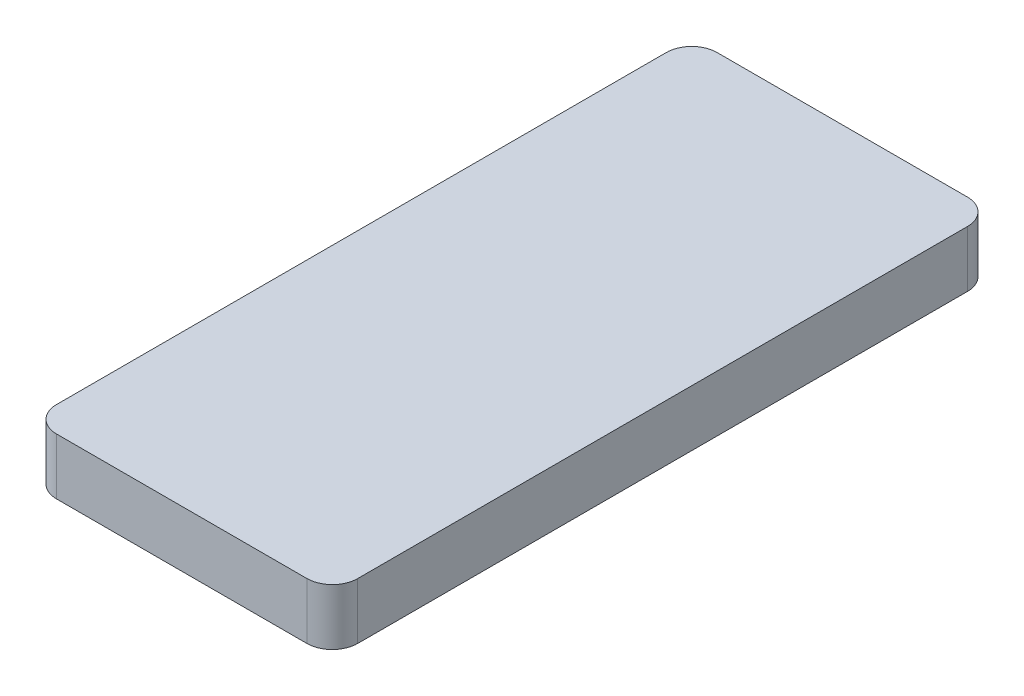
from build123d import *

# Parameters (mm, degrees)
EXTRUDE_1_DEPTH = 15.5
SHELL_1_T       = -2


with BuildPart() as part:
    # Эскиз2 → Бобышка-Вытянуть1 (new body)
    with BuildSketch(Plane(origin=(0, 0, 0), x_dir=(1, 0, 0), z_dir=(0, 1, 0))):
        with BuildLine():
            Line((-7, 0), (-76, 0))
            ThreePointArc((-76, 0), (-80.949747468, 2.050252532), (-83, 7))
            Line((-83, 7), (-83, 175))
            ThreePointArc((-83, 175), (-80.949747468, 179.949747468), (-76, 182))
            Line((-76, 182), (-7, 182))
            ThreePointArc((-7, 182), (-2.050252532, 179.949747468), (0, 175))
            Line((0, 175), (0, 7))
            ThreePointArc((0, 7), (-2.050252532, 2.050252532), (-7, 0))
        make_face()
    extrude(amount=EXTRUDE_1_DEPTH)

    # Оболочка1
    shell_1_openings = [part.faces().sort_by_distance(p)[0] for p in [
        (-41.5, 0, -91),
    ]]
    offset(amount=SHELL_1_T, openings=shell_1_openings, kind=Kind.INTERSECTION)


solid = part.part
